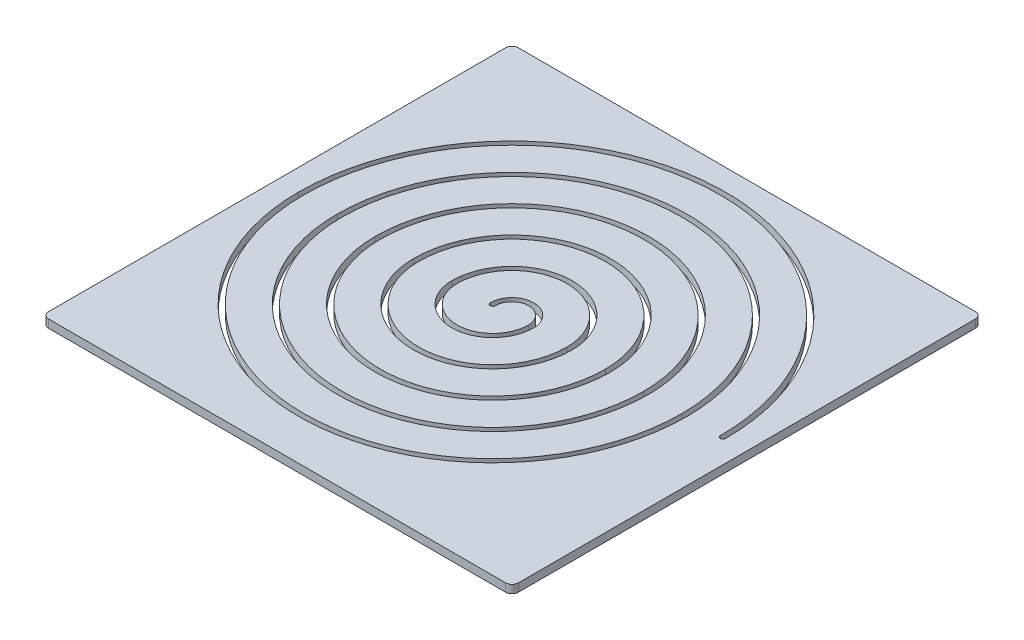
from build123d import *

# Parameters (mm, degrees)
BOSS_EXTRU_1_DEPTH      = 12.7
ENL_V_MAT_EXTRU_1_DEPTH = 13.7


with BuildPart() as part:
    # Esquisse1 → Boss.-Extru.1 (new body)
    with BuildSketch(Plane(origin=(0, 0, 0), x_dir=(1, 0, 0), z_dir=(0, 1, 0))):
        with BuildLine():
            Line((-357.5, 367.5), (357.5, 367.5))
            ThreePointArc((357.5, 367.5), (364.571067812, 364.571067812), (367.5, 357.5))
            Line((367.5, 357.5), (367.5, -357.5))
            ThreePointArc((367.5, -357.5), (364.571067812, -364.571067812), (357.5, -367.5))
            Line((357.5, -367.5), (-357.5, -367.5))
            ThreePointArc((-357.5, -367.5), (-364.571067812, -364.571067812), (-367.5, -357.5))
            Line((-367.5, -357.5), (-367.5, 357.5))
            ThreePointArc((-367.5, 357.5), (-364.571067812, 364.571067812), (-357.5, 367.5))
        make_face()
    extrude(amount=BOSS_EXTRU_1_DEPTH)

    # Esquisse2 → Enlèv. mat.-Extru.1 (cut, through all)
    with BuildSketch(Plane(origin=(0, 12.7, 0), x_dir=(1, 0, 0), z_dir=(0, 1, 0))):
        with BuildLine():
            ThreePointArc((26, 0), (0, 26), (-26, 0))
            ThreePointArc((-26, 0), (-30, -4), (-34, 0))
            ThreePointArc((-34, 0), (0, 34), (34, 0))
            ThreePointArc((34, 0), (-30, -64), (-94, 0))
            ThreePointArc((-94, 0), (0, 94), (94, 0))
            ThreePointArc((94, 0), (-30, -124), (-154, 0))
            ThreePointArc((-154, 0), (0, 154), (154, 0))
            ThreePointArc((154, 0), (-30, -184), (-214, 0))
            ThreePointArc((-214, 0), (0, 214), (214, 0))
            ThreePointArc((214, 0), (-30, -244), (-274, 0))
            ThreePointArc((-274, 0), (0, 274), (274, 0))
            ThreePointArc((274, 0), (-30, -304), (-334, 0))
            ThreePointArc((-334, 0), (0, 334), (334, 0))
            ThreePointArc((334, 0), (330, -4), (326, 0))
            ThreePointArc((326, 0), (0, 326), (-326, 0))
            ThreePointArc((-326, 0), (-30, -296), (266, 0))
            ThreePointArc((266, 0), (0, 266), (-266, 0))
            ThreePointArc((-266, 0), (-30, -236), (206, 0))
            ThreePointArc((206, 0), (0, 206), (-206, 0))
            ThreePointArc((-206, 0), (-30, -176), (146, 0))
            ThreePointArc((146, 0), (0, 146), (-146, 0))
            ThreePointArc((-146, 0), (-30, -116), (86, 0))
            ThreePointArc((86, 0), (0, 86), (-86, 0))
            ThreePointArc((-86, 0), (-30, -56), (26, 0))
        make_face()
    extrude(amount=-ENL_V_MAT_EXTRU_1_DEPTH, mode=Mode.SUBTRACT)


solid = part.part
